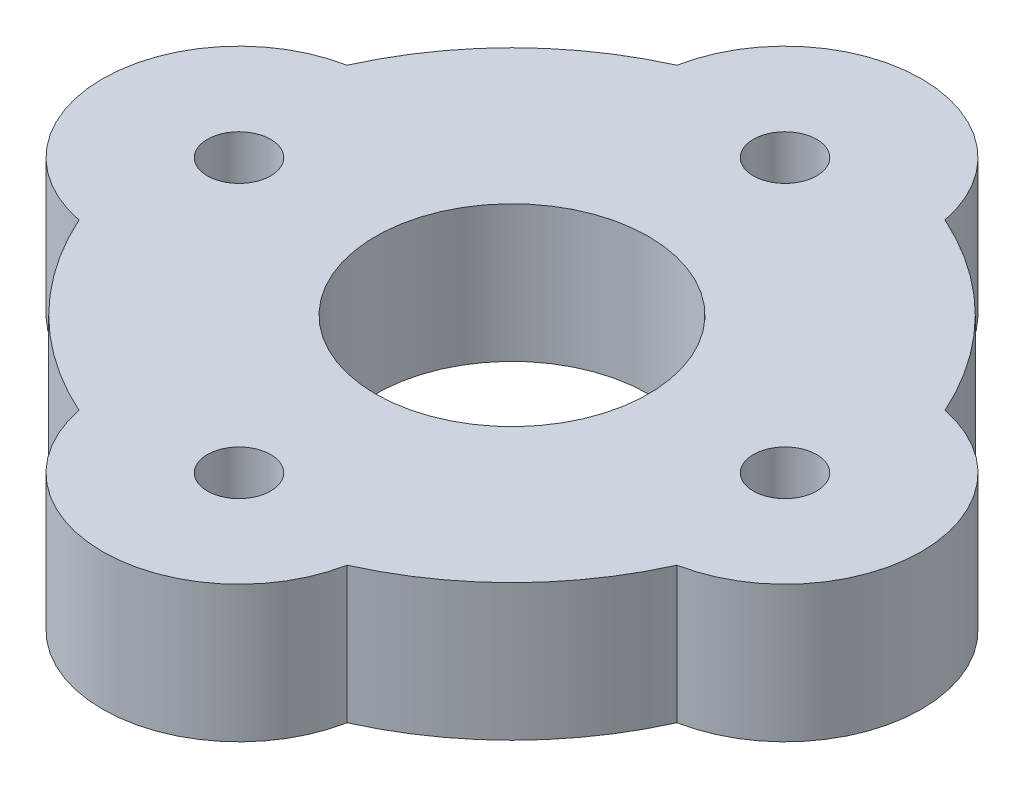
from build123d import *

# Parameters (mm, degrees)
SKETCH1_R                 = 15.24
SKETCH1_R_2               = 6.35
BOSS_EXTRUDE1_DEPTH       = 6.35
F_4_CLEARANCE_HOLE1_D     = 2.9464
F_4_CLEARANCE_HOLE1_DEPTH = 6.35
BOSS_EXTRUDE2_DEPTH       = 6.35
CIRPATTERN1_COUNT         = 4


with BuildPart() as part:
    # Sketch1 → Boss-Extrude1 (new body)
    with BuildSketch(Plane(origin=(0, 0, 0), x_dir=(1, 0, 0), z_dir=(0, 1, 0))):
        Circle(SKETCH1_R)
        Circle(SKETCH1_R_2, mode=Mode.SUBTRACT)
    extrude(amount=BOSS_EXTRUDE1_DEPTH)

    # #4 Clearance Hole1
    with Locations(Plane(origin=(-8.015495471, 6.35, -5.066061758), x_dir=(1, 0, 0), z_dir=(0, 1, 0))):
        with Locations((8.015495471, 7.633938242), (-4.684504529, -5.066061758), (20.715495471, -5.066061758), (8.015495471, -17.766061758)):
            Hole(F_4_CLEARANCE_HOLE1_D / 2, depth=F_4_CLEARANCE_HOLE1_DEPTH)

    # Sketch7 → Boss-Extrude2 (add)
    with BuildSketch(Plane(origin=(0, 6.35, 0), x_dir=(1, 0, 0), z_dir=(0, 1, 0))):
        with BuildLine():
            ThreePointArc((-6.234328974, 13.9065), (0, 19.05), (6.234328974, 13.9065))
            ThreePointArc((6.234328974, 13.9065), (0, 15.24), (-6.234328974, 13.9065))
        make_face()
    boss_extrude2 = extrude(amount=-BOSS_EXTRUDE2_DEPTH)

    # CirPattern1: Boss-Extrude2 ×4 about axis
    cirpattern1_axis = Axis((0, 0, 0), (0, 1, 0))
    for i in range(1, CIRPATTERN1_COUNT):
        add(boss_extrude2.rotate(cirpattern1_axis, i * 360 / CIRPATTERN1_COUNT))


solid = part.part
